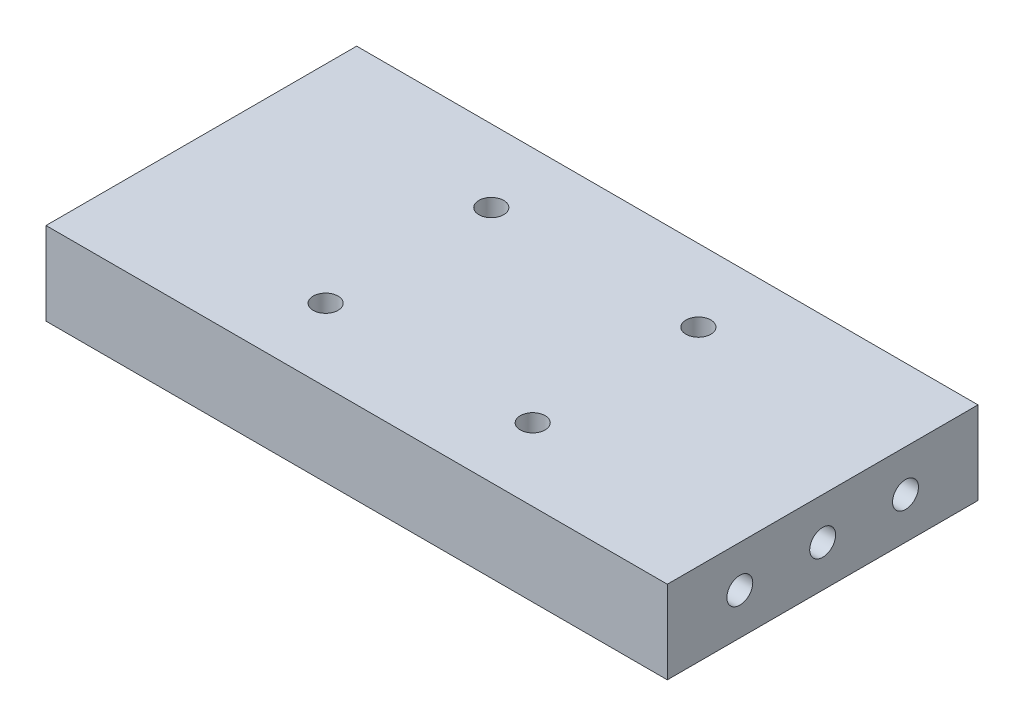
from build123d import *

# Parameters (mm, degrees)
SKETCH_1_W             = 60
SKETCH_1_H             = 30
EXTRUDE_1_DEPTH        = 8
CUT_EXTRUDE_1_REACH    = 10
SKETCH_2_R             = 1.2
HOLE_WIZARD_M3_1_D     = 2.5
HOLE_WIZARD_M3_1_DEPTH = 8.5
HOLE_WIZARD_M3_1_TIP   = 0.751075774
HOLE_WIZARD_M3_2_D     = 2.5
HOLE_WIZARD_M3_2_DEPTH = 8.5
HOLE_WIZARD_M3_2_TIP   = 0.751075774


with BuildPart() as part:
    # 스케치1 → 보스-돌출1 (new body)
    with BuildSketch(Plane(origin=(0, 0, 0), x_dir=(1, 0, 0), z_dir=(0, 1, 0))):
        Rectangle(SKETCH_1_W, SKETCH_1_H)
    extrude(amount=EXTRUDE_1_DEPTH)

    # 스케치2 → 컷-돌출1 (cut, up to next)
    with BuildSketch(Plane(origin=(0, 8, 0), x_dir=(1, 0, 0), z_dir=(0, 1, 0)), mode=Mode.PRIVATE) as cut_extrude_1_sk1:
        with Locations((-10, 8)):
            Circle(SKETCH_2_R)
    cut_extrude_1_tool1 = extrude(cut_extrude_1_sk1.sketch, amount=-CUT_EXTRUDE_1_REACH, mode=Mode.PRIVATE) & part.part
    add(cut_extrude_1_tool1.solids().sort_by_distance((-10, 8, -8))[0], mode=Mode.SUBTRACT)
    # 스케치2 → 컷-돌출1 (cut, up to next)
    with BuildSketch(Plane(origin=(0, 8, 0), x_dir=(1, 0, 0), z_dir=(0, 1, 0)), mode=Mode.PRIVATE) as cut_extrude_1_sk2:
        with Locations((10, 8)):
            Circle(SKETCH_2_R)
    cut_extrude_1_tool2 = extrude(cut_extrude_1_sk2.sketch, amount=-CUT_EXTRUDE_1_REACH, mode=Mode.PRIVATE) & part.part
    add(cut_extrude_1_tool2.solids().sort_by_distance((10, 8, -8))[0], mode=Mode.SUBTRACT)
    # 스케치2 → 컷-돌출1 (cut, up to next)
    with BuildSketch(Plane(origin=(0, 8, 0), x_dir=(1, 0, 0), z_dir=(0, 1, 0)), mode=Mode.PRIVATE) as cut_extrude_1_sk3:
        with Locations((10, -8)):
            Circle(SKETCH_2_R)
    cut_extrude_1_tool3 = extrude(cut_extrude_1_sk3.sketch, amount=-CUT_EXTRUDE_1_REACH, mode=Mode.PRIVATE) & part.part
    add(cut_extrude_1_tool3.solids().sort_by_distance((10, 8, 8))[0], mode=Mode.SUBTRACT)
    # 스케치2 → 컷-돌출1 (cut, up to next)
    with BuildSketch(Plane(origin=(0, 8, 0), x_dir=(1, 0, 0), z_dir=(0, 1, 0)), mode=Mode.PRIVATE) as cut_extrude_1_sk4:
        with Locations((-10, -8)):
            Circle(SKETCH_2_R)
    cut_extrude_1_tool4 = extrude(cut_extrude_1_sk4.sketch, amount=-CUT_EXTRUDE_1_REACH, mode=Mode.PRIVATE) & part.part
    add(cut_extrude_1_tool4.solids().sort_by_distance((-10, 8, 8))[0], mode=Mode.SUBTRACT)

    # M3 나사 구멍1
    with Locations(Plane.ZY.offset(30)):
        with Locations((-8, 4), (0, 4), (8, 4)):
            Hole(HOLE_WIZARD_M3_1_D / 2, depth=HOLE_WIZARD_M3_1_DEPTH)
            with Locations((0, 0, -(HOLE_WIZARD_M3_1_DEPTH + HOLE_WIZARD_M3_1_TIP / 2))):  # 118° drill point
                Cone(0, HOLE_WIZARD_M3_1_D / 2, HOLE_WIZARD_M3_1_TIP, mode=Mode.SUBTRACT)

    # M3 나사 구멍2
    with Locations(Plane(origin=(30, 0, 0), x_dir=(0, 0, -1), z_dir=(1, 0, 0))):
        with Locations((-8, 4), (0, 4), (8, 4)):
            Hole(HOLE_WIZARD_M3_2_D / 2, depth=HOLE_WIZARD_M3_2_DEPTH)
            with Locations((0, 0, -(HOLE_WIZARD_M3_2_DEPTH + HOLE_WIZARD_M3_2_TIP / 2))):  # 118° drill point
                Cone(0, HOLE_WIZARD_M3_2_D / 2, HOLE_WIZARD_M3_2_TIP, mode=Mode.SUBTRACT)


solid = part.part
